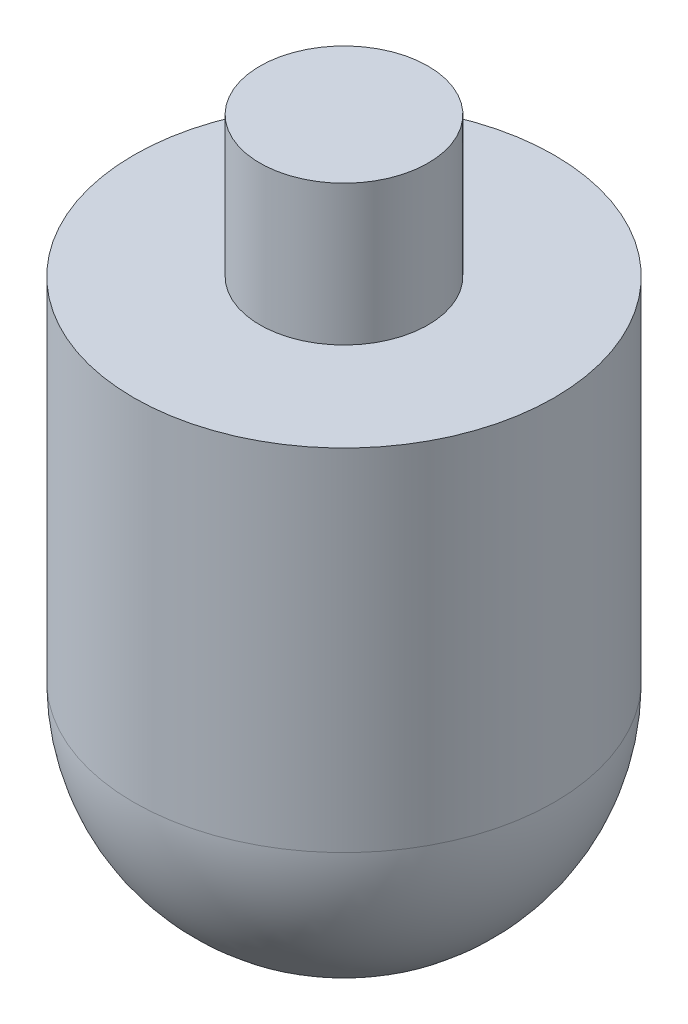
from build123d import *


with BuildPart() as part:
    # Sketch1 → Revolve1 (revolve)
    with BuildSketch(Plane.XY, mode=Mode.PRIVATE) as revolve1_sk:
        with BuildLine():
            Line((0, 35), (6, 35))
            Line((6, 35), (6, 25))
            Line((6, 25), (15, 25))
            Line((15, 25), (15, 0))
            ThreePointArc((15, 0), (10.606601718, -10.606601718), (0, -15))
            Line((0, -15), (0, 35))
        make_face()
    revolve(revolve1_sk.sketch.rotate(Axis((0, 0, 0), (0, 1, 0)), 90), axis=Axis((0, 0, 0), (0, 1, 0)))  # turned: the seam where the file's is


solid = part.part
